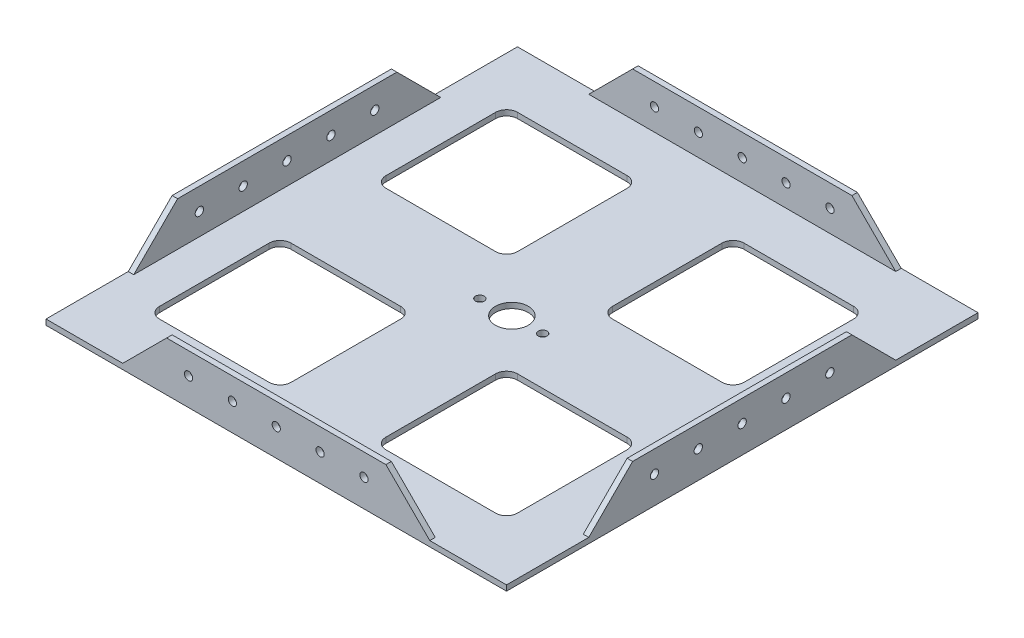
from build123d import *

# Parameters (mm, degrees)
SKETCH2_W           = 266.7
SKETCH2_H           = 273.05
BOSS_EXTRUDE1_DEPTH = 3.175
SKETCH3_R           = 9.525
CUT_EXTRUDE1_DEPTH  = 4.175
SKETCH4_W           = 76.2
SKETCH4_H           = 76.2
CUT_EXTRUDE2_DEPTH  = 4.175
FILLET2_R           = 6.35
SKETCH5_W           = 177.8
SKETCH5_H           = 3.175
SKETCH5_W_2         = 3.175
SKETCH5_H_2         = 177.8
BOSS_EXTRUDE2_DEPTH = 25.4
CUT_EXTRUDE3_DEPTH  = 267.7
CUT_EXTRUDE4_DEPTH  = 274.05
SKETCH8_R           = 2.54
CUT_EXTRUDE5_DEPTH  = 4.175
SKETCH10_R          = 2.38125
CUT_EXTRUDE6_DEPTH  = 274.05
SKETCH11_R          = 2.413
CUT_EXTRUDE7_DEPTH  = 267.7


with BuildPart() as part:
    # Sketch2 → Boss-Extrude1 (new body)
    with BuildSketch(Plane(origin=(0, 0, 0), x_dir=(1, 0, 0), z_dir=(0, 1, 0))):
        with Locations((133.35, 136.525)):
            Rectangle(SKETCH2_W, SKETCH2_H)
    extrude(amount=BOSS_EXTRUDE1_DEPTH)

    # Sketch3 → Cut-Extrude1 (cut, through all)
    with BuildSketch(Plane(origin=(0, 3.175, 0), x_dir=(1, 0, 0), z_dir=(0, 1, 0))):
        with Locations((133.262465238, 136.525)):
            Circle(SKETCH3_R)
    extrude(amount=-CUT_EXTRUDE1_DEPTH, mode=Mode.SUBTRACT)

    # Sketch4 → Cut-Extrude2 (cut, through all)
    with BuildSketch(Plane(origin=(0, 3.175, 0), x_dir=(1, 0, 0), z_dir=(0, 1, 0))):
        with Locations((64.623665915, 202.110512242)):
            Rectangle(SKETCH4_W, SKETCH4_H)
        with Locations((195.760512242, 202.110512242)):
            Rectangle(SKETCH4_W, SKETCH4_H)
        with Locations((64.623665915, 70.939487758)):
            Rectangle(SKETCH4_W, SKETCH4_H)
        with Locations((195.760512242, 70.939487758)):
            Rectangle(SKETCH4_W, SKETCH4_H)
    extrude(amount=-CUT_EXTRUDE2_DEPTH, mode=Mode.SUBTRACT)

    # Fillet2
    fillet2_edges = [part.edges().sort_by_distance(p)[0] for p in [
        (26.523665915, 1.5875, -164.010512242),
        (26.523665915, 1.5875, -240.210512242),
        (102.723665915, 1.5875, -240.210512242),
        (102.723665915, 1.5875, -164.010512242),
        (157.660512242, 1.5875, -164.010512242),
        (157.660512242, 1.5875, -240.210512242),
        (233.860512242, 1.5875, -240.210512242),
        (233.860512242, 1.5875, -164.010512242),
        (26.523665915, 1.5875, -32.839487758),
        (26.523665915, 1.5875, -109.039487758),
        (102.723665915, 1.5875, -109.039487758),
        (102.723665915, 1.5875, -32.839487758),
        (157.660512242, 1.5875, -32.839487758),
        (157.660512242, 1.5875, -109.039487758),
        (233.860512242, 1.5875, -109.039487758),
        (233.860512242, 1.5875, -32.839487758),
    ]]
    fillet(fillet2_edges, radius=FILLET2_R)

    # Sketch5 → Boss-Extrude2 (add)
    with BuildSketch(Plane(origin=(0, 3.175, 0), x_dir=(1, 0, 0), z_dir=(0, 1, 0))):
        with Locations((133.35, 271.4625)):
            Rectangle(SKETCH5_W, SKETCH5_H)
        with Locations((133.35, 1.5875)):
            Rectangle(SKETCH5_W, SKETCH5_H)
        with Locations((265.1125, 136.525)):
            Rectangle(SKETCH5_W_2, SKETCH5_H_2)
        with Locations((1.5875, 136.525)):
            Rectangle(SKETCH5_W_2, SKETCH5_H_2)
    extrude(amount=BOSS_EXTRUDE2_DEPTH)

    # Sketch6 → Cut-Extrude3 (cut, through all)
    with BuildSketch(Plane(origin=(266.7, 0, 0), x_dir=(0, 0, -1), z_dir=(1, 0, 0))):
        Polygon((47.625, 3.175), (73.025, 28.575), (47.625, 28.575), align=None)
        Polygon((225.425, 3.175), (200.025, 28.575), (225.425, 28.575), align=None)
    extrude(amount=-CUT_EXTRUDE3_DEPTH, mode=Mode.SUBTRACT)

    # Sketch7 → Cut-Extrude4 (cut, through all)
    with BuildSketch(Plane.XY):
        Polygon((44.45, 3.175), (69.85, 28.575), (44.45, 28.575), align=None)
        Polygon((222.25, 3.175), (196.85, 28.575), (222.25, 28.575), align=None)
    extrude(amount=-CUT_EXTRUDE4_DEPTH, mode=Mode.SUBTRACT)

    # Sketch8 → Cut-Extrude5 (cut, through all)
    with BuildSketch(Plane(origin=(0, 3.175, 0), x_dir=(1, 0, 0), z_dir=(0, 1, 0))):
        with Locations((151.118665238, 136.525)):
            Circle(SKETCH8_R)
        with Locations((115.406265238, 135.851510726)):
            Circle(SKETCH8_R)
    extrude(amount=-CUT_EXTRUDE5_DEPTH, mode=Mode.SUBTRACT)

    # Sketch10 → Cut-Extrude6 (cut, through all)
    with BuildSketch(Plane.XY):
        with Locations((133.35, 15.875)):
            Circle(SKETCH10_R)
        with Locations((158.75, 15.875)):
            Circle(SKETCH10_R)
        with Locations((107.95, 15.875)):
            Circle(SKETCH10_R)
        with Locations((82.55, 15.875)):
            Circle(SKETCH10_R)
        with Locations((184.15, 15.875)):
            Circle(SKETCH10_R)
    extrude(amount=-CUT_EXTRUDE6_DEPTH, mode=Mode.SUBTRACT)

    # Sketch11 → Cut-Extrude7 (cut, through all)
    with BuildSketch(Plane(origin=(266.7, 0, 0), x_dir=(0, 0, -1), z_dir=(1, 0, 0))):
        with Locations((136.4488, 15.875)):
            Circle(SKETCH11_R)
        with Locations((111.0488, 15.875)):
            Circle(SKETCH11_R)
        with Locations((85.6488, 15.875)):
            Circle(SKETCH11_R)
        with Locations((161.8488, 15.875)):
            Circle(SKETCH11_R)
        with Locations((187.2488, 15.875)):
            Circle(SKETCH11_R)
    extrude(amount=-CUT_EXTRUDE7_DEPTH, mode=Mode.SUBTRACT)


solid = part.part
